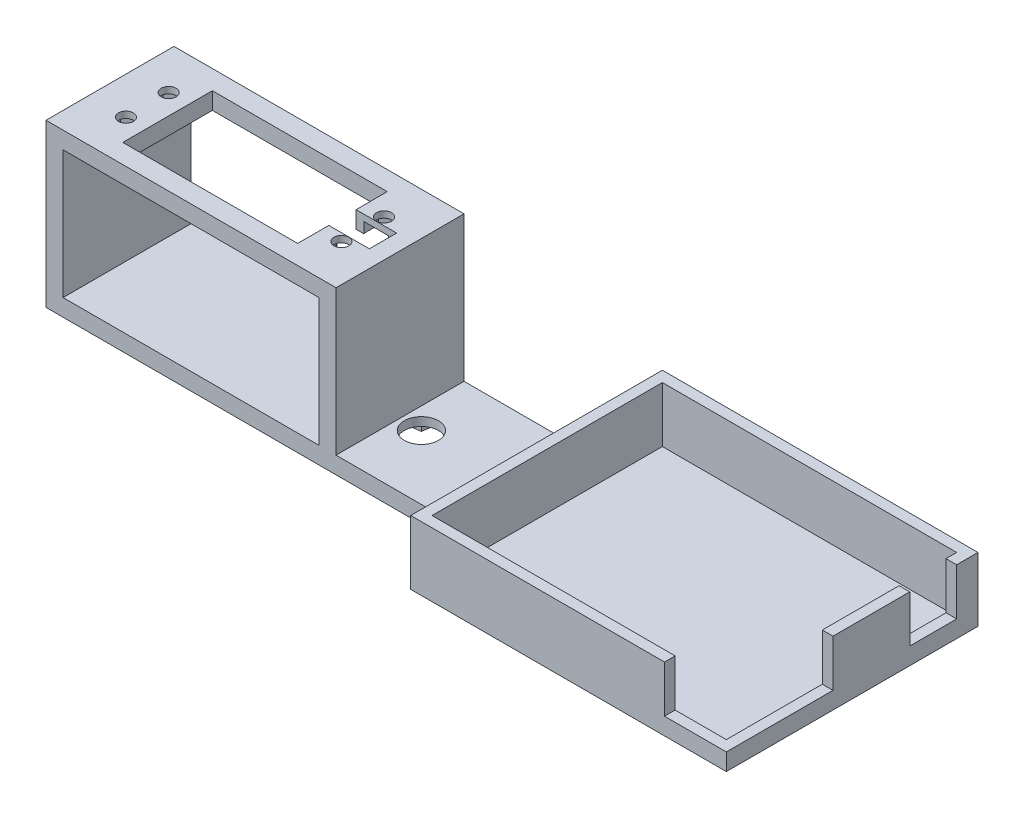
from build123d import *

# Parameters (mm, degrees)
SKETCH1_W           = 74
SKETCH1_H           = 59
BOSS_EXTRUDE1_DEPTH = 2
SKETCH2_W           = 74
SKETCH2_H           = 59
SKETCH2_W_2         = 69
SKETCH2_H_2         = 54
BOSS_EXTRUDE2_DEPTH = 2
SKETCH3_W           = 2.5
SKETCH3_H           = 18
BOSS_EXTRUDE3_DEPTH = 11
SKETCH4_W           = 30
SKETCH4_H           = 4
BOSS_EXTRUDE4_DEPTH = 100
SKETCH5_W           = 4
SKETCH5_H           = 30
BOSS_EXTRUDE5_DEPTH = 30
SKETCH6_W           = 68
SKETCH6_H           = 30
SKETCH6_W_2         = 41
SKETCH6_H_2         = 21
BOSS_EXTRUDE6_DEPTH = 4
SKETCH7_R           = 1.75
SKETCH7_W           = 9.5
SKETCH7_H           = 6.4
CUT_EXTRUDE1_DEPTH  = 5
CUT_EXTRUDE2_DEPTH  = 2.5
SKETCH9_R           = 4
CUT_EXTRUDE3_DEPTH  = 10
SKETCH10_RX         = 12.5
SKETCH10_RY         = 4
CUT_EXTRUDE4_DEPTH  = 2


with BuildPart() as part:
    # Sketch1 → Boss-Extrude1 (new body)
    with BuildSketch(Plane(origin=(0, 0, 0), x_dir=(1, 0, 0), z_dir=(0, 1, 0))):
        Rectangle(SKETCH1_W, SKETCH1_H)
    extrude(amount=BOSS_EXTRUDE1_DEPTH)

    # Sketch2 → Boss-Extrude2 (add)
    with BuildSketch(Plane(origin=(0, 2, 0), x_dir=(1, 0, 0), z_dir=(0, 1, 0))):
        Rectangle(SKETCH2_W, SKETCH2_H)
        Rectangle(SKETCH2_W_2, SKETCH2_H_2, mode=Mode.SUBTRACT)
    extrude(amount=BOSS_EXTRUDE2_DEPTH)

    # Sketch3 → Boss-Extrude3 (add)
    with BuildSketch(Plane(origin=(0, 4, 0), x_dir=(1, 0, 0), z_dir=(0, 1, 0))):
        Polygon((22.5, -27), (22.5, -29.5), (-37, -29.5), (-37, 29.5), (37, 29.5), (37, 24.5), (34.5, 24.5), (34.5, 27), (-34.5, 27), (-34.5, -27), align=None)
        with Locations((35.75, 4.5)):
            Rectangle(SKETCH3_W, SKETCH3_H)
    extrude(amount=BOSS_EXTRUDE3_DEPTH)

    # Sketch4 → Boss-Extrude4 (add)
    with BuildSketch(Plane.ZY.offset(37)):
        with Locations((0, 2)):
            Rectangle(SKETCH4_W, SKETCH4_H)
    extrude(amount=BOSS_EXTRUDE4_DEPTH)

    # Sketch5 → Boss-Extrude5 (add)
    with BuildSketch(Plane(origin=(0, 4, 0), x_dir=(1, 0, 0), z_dir=(0, 1, 0))):
        with Locations((-71, 0)):
            Rectangle(SKETCH5_W, SKETCH5_H)
        with Locations((-135, 0)):
            Rectangle(SKETCH5_W, SKETCH5_H)
    extrude(amount=BOSS_EXTRUDE5_DEPTH)

    # Sketch6 → Boss-Extrude6 (add)
    with BuildSketch(Plane(origin=(0, 34, 0), x_dir=(1, 0, 0), z_dir=(0, 1, 0))):
        with Locations((-103, 0)):
            Rectangle(SKETCH6_W, SKETCH6_H)
        with Locations((-103, 0)):
            Rectangle(SKETCH6_W_2, SKETCH6_H_2, mode=Mode.SUBTRACT)
    extrude(amount=BOSS_EXTRUDE6_DEPTH)

    # Sketch7 → Cut-Extrude1 (cut)
    with BuildSketch(Plane(origin=(0, 38, 0), x_dir=(1, 0, 0), z_dir=(0, 1, 0))):
        with Locations((-128.25, 5)):
            Circle(SKETCH7_R)
        with Locations((-77.75, 5)):
            Circle(SKETCH7_R)
        with Locations((-77.75, -5)):
            Circle(SKETCH7_R)
        with Locations((-128.25, -5)):
            Circle(SKETCH7_R)
        with Locations((-77.75, 0)):
            Rectangle(SKETCH7_W, SKETCH7_H)
    extrude(amount=-CUT_EXTRUDE1_DEPTH, mode=Mode.SUBTRACT)

    # Sketch8 → Cut-Extrude2 (cut)
    with BuildSketch(Plane.XZ.offset(-34)):
        Polygon((-131.25, 6.732050808), (-131.25, 3.267949192), (-128.25, 1.535898385), (-125.25, 3.267949192), (-125.25, 6.732050808), (-128.25, 8.464101615), align=None)
        Polygon((-128.25, -1.535898385), (-131.25, -3.267949192), (-131.25, -6.732050808), (-128.25, -8.464101615), (-125.25, -6.732050808), (-125.25, -3.267949192), align=None)
        Polygon((-74.75, 3.267949192), (-74.75, 6.732050808), (-77.75, 8.464101615), (-80.75, 6.732050808), (-80.75, 3.267949192), (-77.75, 1.535898385), align=None)
        Polygon((-74.75, -6.732050808), (-74.75, -3.267949192), (-77.75, -1.535898385), (-80.75, -3.267949192), (-80.75, -6.732050808), (-77.75, -8.464101615), align=None)
    extrude(amount=-CUT_EXTRUDE2_DEPTH, mode=Mode.SUBTRACT)

    # Sketch9 → Cut-Extrude3 (cut)
    with BuildSketch(Plane(origin=(0, 4, 0), x_dir=(1, 0, 0), z_dir=(0, 1, 0))):
        with Locations((-64, 0)):
            Circle(SKETCH9_R)
    extrude(amount=-CUT_EXTRUDE3_DEPTH, mode=Mode.SUBTRACT)

    # Sketch10 → Cut-Extrude4 (cut)
    with BuildSketch(Plane.XZ):
        with Locations(Location((-64, 0), (0, 0, 90))):
            Ellipse(SKETCH10_RX, SKETCH10_RY)
        with Locations((-64, 0)):
            Ellipse(SKETCH10_RX, SKETCH10_RY)
    extrude(amount=-CUT_EXTRUDE4_DEPTH, mode=Mode.SUBTRACT)


solid = part.part
